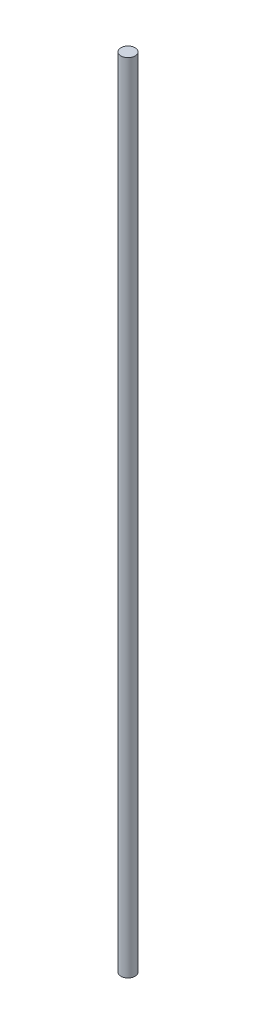
from build123d import *

# Parameters (mm, degrees)
SKETCH1_R           = 2.5
BOSS_EXTRUDE1_DEPTH = 279.4


with BuildPart() as part:
    # Sketch1 → Boss-Extrude1 (new body)
    with BuildSketch(Plane(origin=(0, 0, 0), x_dir=(1, 0, 0), z_dir=(0, 1, 0))):
        Circle(SKETCH1_R)
    extrude(amount=BOSS_EXTRUDE1_DEPTH)


solid = part.part
